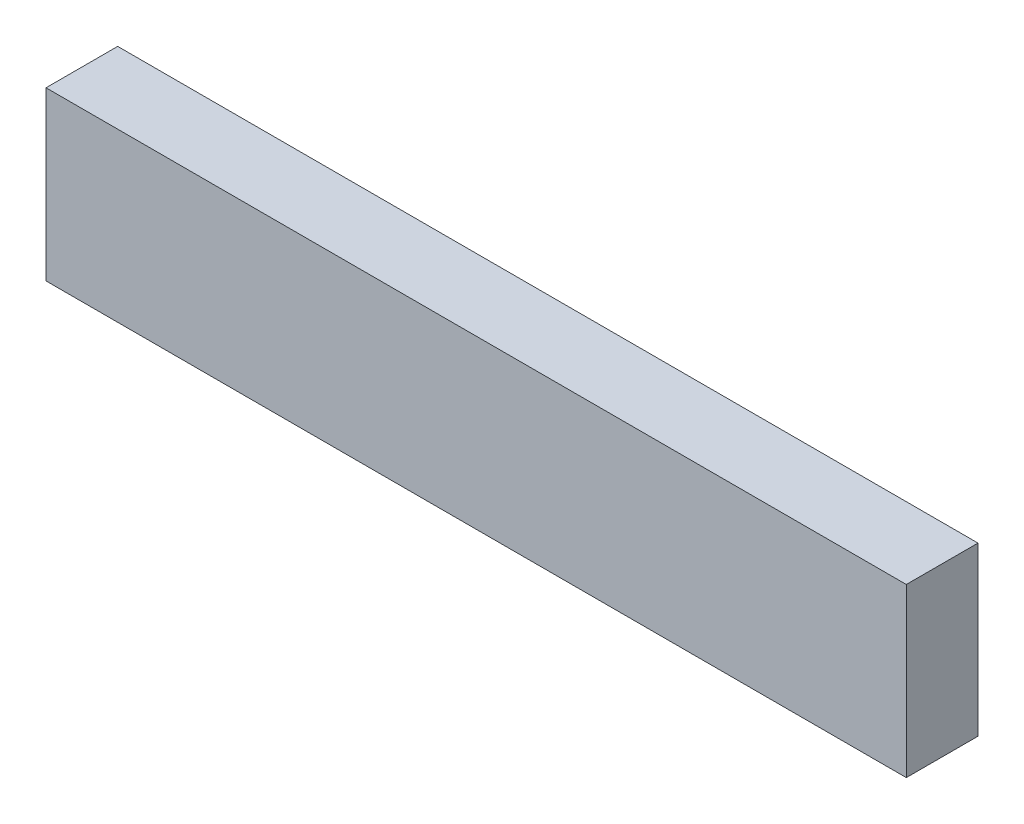
from build123d import *

# Parameters (mm, degrees)
SKETCH1_W           = 457.2
SKETCH1_H           = 88.9
BOSS_EXTRUDE1_DEPTH = 38.1


with BuildPart() as part:
    # Sketch1 → Boss-Extrude1 (new body)
    with BuildSketch(Plane.XY):
        Rectangle(SKETCH1_W, SKETCH1_H)
    extrude(amount=BOSS_EXTRUDE1_DEPTH)


solid = part.part
